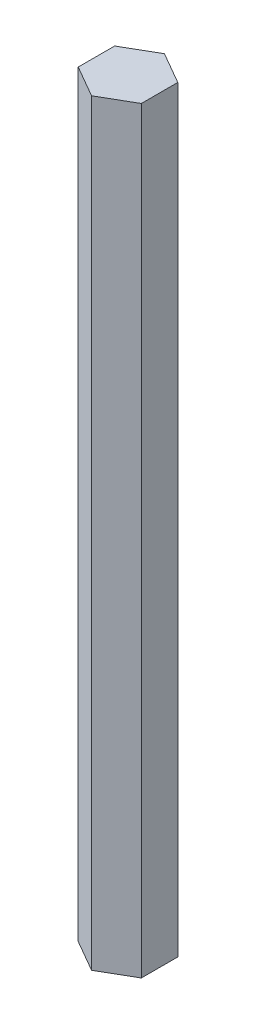
from build123d import *

# Parameters (mm, degrees)
BOSS_EXTRUDE2_DEPTH = 152.4


with BuildPart() as part:
    # Sketch1 → Boss-Extrude2 (new body)
    with BuildSketch(Plane(origin=(0, 0, 0), x_dir=(1, 0, 0), z_dir=(0, 1, 0))):
        Polygon((6.35, 3.666174209), (0, 7.332348419), (-6.35, 3.666174209), (-6.35, -3.666174209), (0, -7.332348419), (6.35, -3.666174209), align=None)
    extrude(amount=BOSS_EXTRUDE2_DEPTH)


solid = part.part
